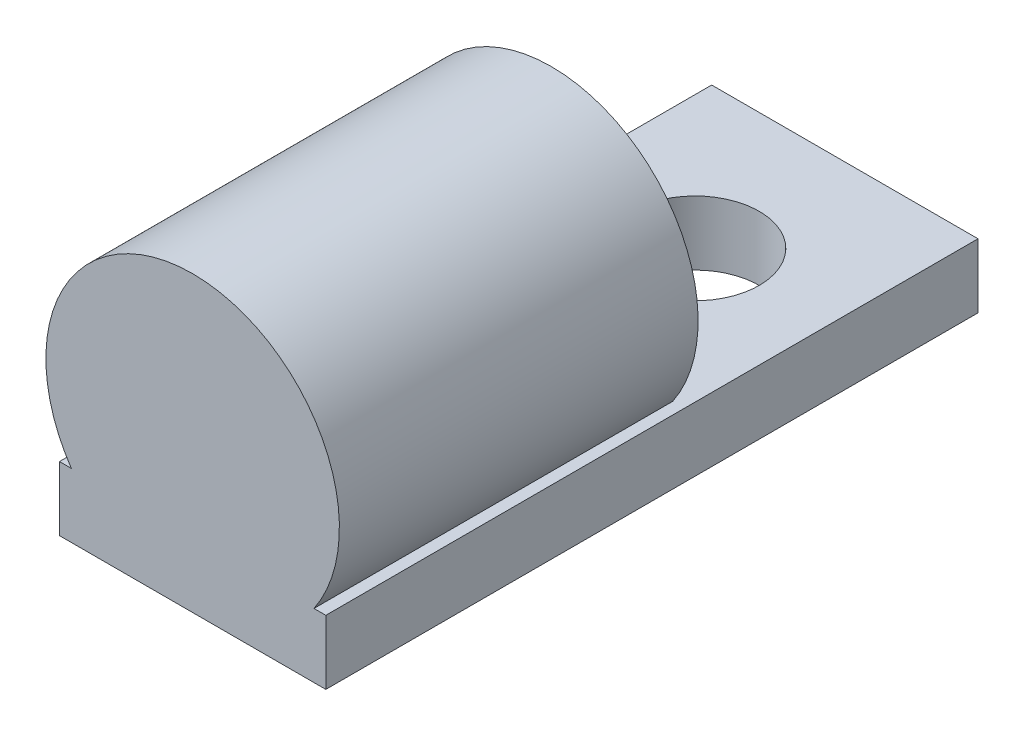
from build123d import *

# Parameters (mm, degrees)
SKETCH1_W           = 12.446
SKETCH1_H           = 30.48
SKETCH1_R           = 3
BOSS_EXTRUDE1_DEPTH = 3
SKETCH2_R           = 6.858
BOSS_EXTRUDE2_DEPTH = 16.764


with BuildPart() as part:
    # Sketch1 → Boss-Extrude1 (new body)
    with BuildSketch(Plane(origin=(0, 0, 0), x_dir=(1, 0, 0), z_dir=(0, 1, 0))):
        Rectangle(SKETCH1_W, SKETCH1_H)
        with Locations((0, 8.24)):
            Circle(SKETCH1_R, mode=Mode.SUBTRACT)
    extrude(amount=BOSS_EXTRUDE1_DEPTH)

    # Sketch2 → Boss-Extrude2 (add)
    with BuildSketch(Plane.XY.offset(15.24)):
        with Locations((0, 6.858)):
            Circle(SKETCH2_R)
    extrude(amount=-BOSS_EXTRUDE2_DEPTH)


solid = part.part
